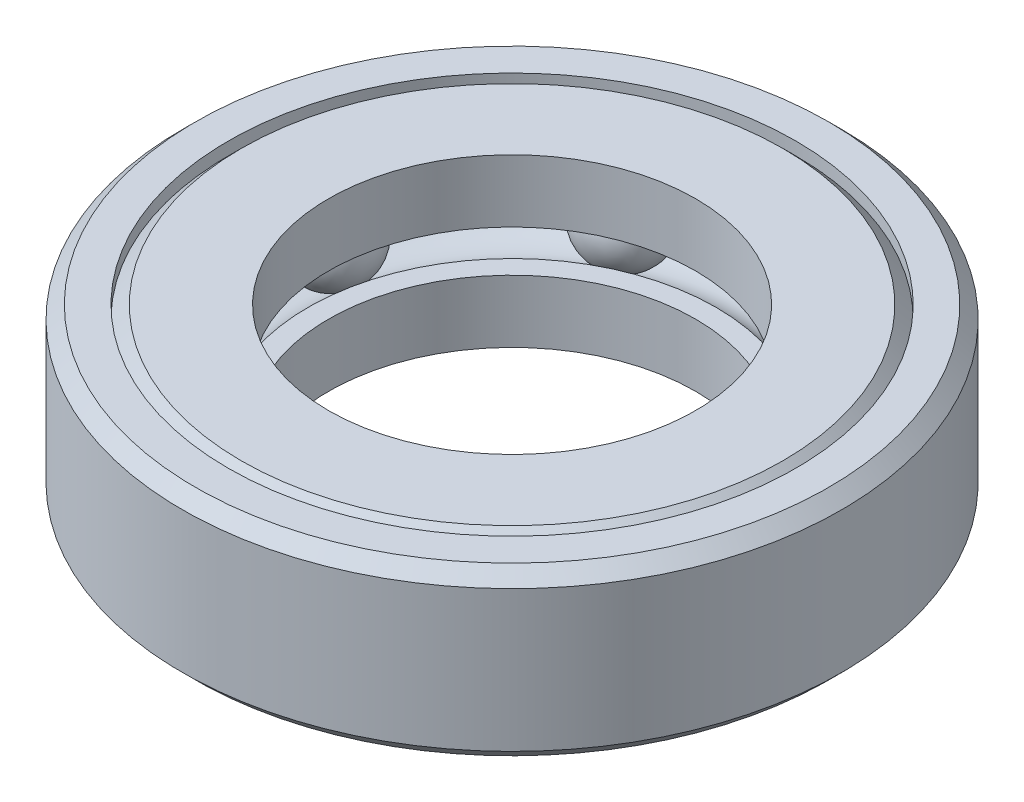
from build123d import *

# Parameters (mm, degrees)
CIRPATTERN1_COUNT = 7


with BuildPart() as part:
    # Sketch2 → Revolve1 (revolve)
    with BuildSketch(Plane(origin=(0, 0, 0), x_dir=(0, 0, -1), z_dir=(1, 0, 0))):
        with BuildLine():
            Line((-26.277194571, 1.984375), (-28.2178125, 1.984375))
            Line((-28.2178125, 1.984375), (-28.2178125, 5.471634886))
            Line((-28.2178125, 5.471634886), (-25.751947386, 7.9375))
            Line((-25.751947386, 7.9375), (-17.4625, 7.9375))
            Line((-17.4625, 7.9375), (-17.4625, 1.984375))
            Line((-17.4625, 1.984375), (-19.403117929, 1.984375))
            ThreePointArc((-19.403117929, 1.984375), (-22.84015625, 3.96875), (-26.277194571, 1.984375))
        make_face()
        with BuildLine():
            Line((-17.4625, -1.984375), (-19.403117929, -1.984375))
            ThreePointArc((-19.403117929, -1.984375), (-22.84015625, -3.96875), (-26.277194571, -1.984375))
            Line((-26.277194571, -1.984375), (-28.2178125, -1.984375))
            Line((-28.2178125, -1.984375), (-28.2178125, -5.471634886))
            Line((-28.2178125, -5.471634886), (-25.751947386, -7.9375))
            Line((-25.751947386, -7.9375), (-17.4625, -7.9375))
            Line((-17.4625, -7.9375), (-17.4625, -1.984375))
        make_face()
    revolve(axis=Axis((0, -7.9375, 0), (0, 1, 0)))


with BuildPart() as body_2:
    # Sketch3 → Revolve2 (revolve)
    with BuildSketch(Plane(origin=(0, 0, 0), x_dir=(0, 0, -1), z_dir=(1, 0, 0))):
        Polygon((-26.984879943, 6.704567443), (-26.984879943, 7.9375), (-30.120192443, 7.9375), (-31.353125, 6.704567443), (-31.353125, -6.704567443), (-30.120192443, -7.9375), (-26.984879943, -7.9375), (-26.984879943, -6.704567443), (-28.2178125, -5.471634886), (-28.2178125, 5.471634886), align=None)
    revolve(axis=Axis((0, -7.9375, 0), (0, 1, 0)))


with BuildPart() as body_3:
    # Sketch4 → Revolve3 (revolve)
    with BuildSketch(Plane(origin=(0, 0, 0), x_dir=(0, 0, -1), z_dir=(1, 0, 0))):
        with BuildLine():
            Line((-22.84015625, 3.96875), (-22.84015625, -3.96875))
            ThreePointArc((-22.84015625, -3.96875), (-18.87140625, 0), (-22.84015625, 3.96875))
        make_face()
    revolve(axis=Axis((0, 3.96875, 22.84015625), (0, -1, 0)))


with BuildPart() as cirpattern1_1:
    # CirPattern1: pattern copy
    add(body_3.part.rotate(Axis((0, 0, 0), (0, 1, 0)), 1 * 360 / CIRPATTERN1_COUNT))


with BuildPart() as cirpattern1_2:
    # CirPattern1: pattern copy
    add(body_3.part.rotate(Axis((0, 0, 0), (0, 1, 0)), 2 * 360 / CIRPATTERN1_COUNT))


with BuildPart() as cirpattern1_3:
    # CirPattern1: pattern copy
    add(body_3.part.rotate(Axis((0, 0, 0), (0, 1, 0)), 3 * 360 / CIRPATTERN1_COUNT))


with BuildPart() as cirpattern1_4:
    # CirPattern1: pattern copy
    add(body_3.part.rotate(Axis((0, 0, 0), (0, 1, 0)), 4 * 360 / CIRPATTERN1_COUNT))


with BuildPart() as cirpattern1_5:
    # CirPattern1: pattern copy
    add(body_3.part.rotate(Axis((0, 0, 0), (0, 1, 0)), 5 * 360 / CIRPATTERN1_COUNT))


with BuildPart() as cirpattern1_6:
    # CirPattern1: pattern copy
    add(body_3.part.rotate(Axis((0, 0, 0), (0, 1, 0)), 6 * 360 / CIRPATTERN1_COUNT))


solid = Compound([part.part, body_2.part, body_3.part, cirpattern1_1.part, cirpattern1_2.part, cirpattern1_3.part, cirpattern1_4.part, cirpattern1_5.part, cirpattern1_6.part])
